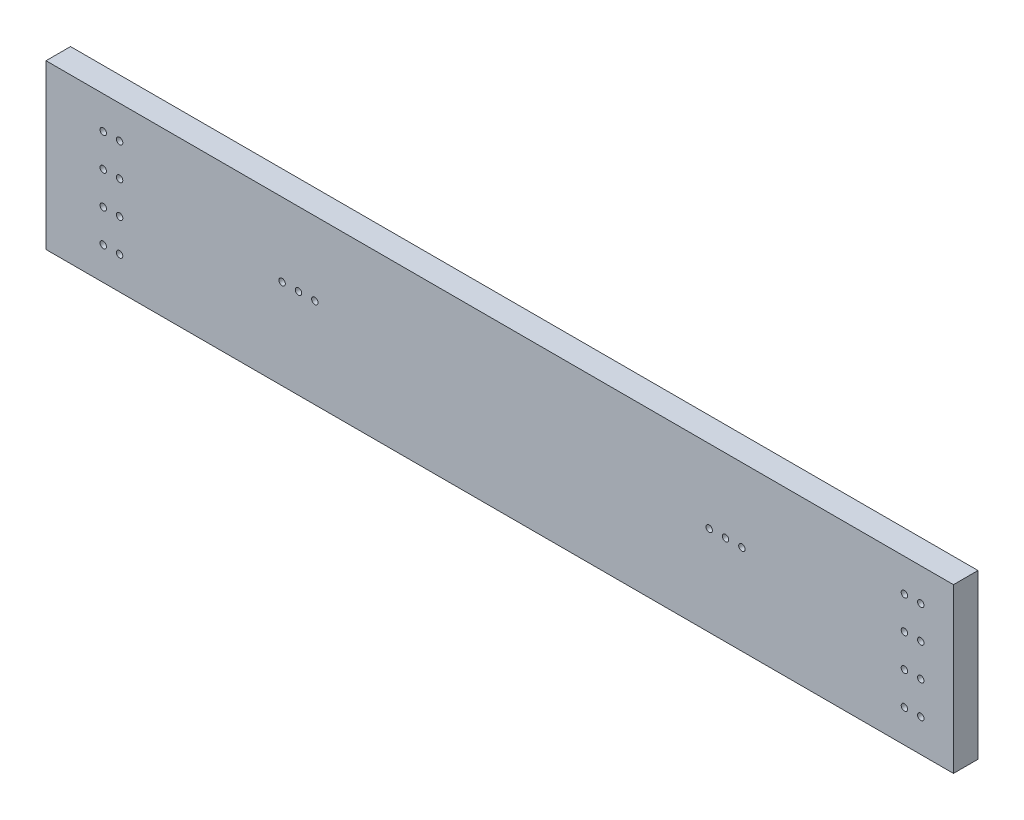
from build123d import *

# Parameters (mm, degrees)
BOSS_EXTRUDE1_START = -57.15
SKETCH4_W           = 704.85
SKETCH4_H           = 19.05
BOSS_EXTRUDE1_DEPTH = 127
SKETCH5_R           = 2.49555
SKETCH5_R_2         = 2.4892
CUT_EXTRUDE1_DEPTH  = 20.05


with BuildPart() as part:
    # Sketch4 → Boss-Extrude1 (new body)
    with BuildSketch(Plane(origin=(0, 0, 0), x_dir=(1, 0, 0), z_dir=(0, 1, 0)).offset(BOSS_EXTRUDE1_START)):
        with Locations((-9.525, -22.225)):
            Rectangle(SKETCH4_W, SKETCH4_H)
    extrude(amount=BOSS_EXTRUDE1_DEPTH)

    # Sketch5 → Cut-Extrude1 (cut, through all)
    with BuildSketch(Plane.XY.offset(31.75)):
        with Locations((-317.5, 44.45)):
            Circle(SKETCH5_R)
        with Locations((-304.8, 44.45)):
            Circle(SKETCH5_R)
        with Locations((-317.5, 19.05)):
            Circle(SKETCH5_R)
        with Locations((-304.8, 19.05)):
            Circle(SKETCH5_R)
        with Locations((-317.5, -6.35)):
            Circle(SKETCH5_R)
        with Locations((-304.8, -6.35)):
            Circle(SKETCH5_R)
        with Locations((-317.5, -31.75)):
            Circle(SKETCH5_R)
        with Locations((-304.8, -31.75)):
            Circle(SKETCH5_R)
        with Locations((304.8, 44.45)):
            Circle(SKETCH5_R)
        with Locations((317.5, 44.45)):
            Circle(SKETCH5_R)
        with Locations((-178.562, 12.7)):
            Circle(SKETCH5_R_2)
        with Locations((-165.862, 12.7)):
            Circle(SKETCH5_R_2)
        with Locations((-153.162, 12.7)):
            Circle(SKETCH5_R_2)
        with Locations((153.162, 12.7)):
            Circle(SKETCH5_R_2)
        with Locations((165.862, 12.7)):
            Circle(SKETCH5_R_2)
        with Locations((178.562, 12.7)):
            Circle(SKETCH5_R_2)
        with Locations((317.5, 19.05)):
            Circle(SKETCH5_R)
        with Locations((304.8, 19.05)):
            Circle(SKETCH5_R)
        with Locations((317.5, -6.35)):
            Circle(SKETCH5_R)
        with Locations((304.8, -6.35)):
            Circle(SKETCH5_R)
        with Locations((317.5, -31.75)):
            Circle(SKETCH5_R)
        with Locations((304.8, -31.75)):
            Circle(SKETCH5_R)
    extrude(amount=-CUT_EXTRUDE1_DEPTH, mode=Mode.SUBTRACT)


solid = part.part
